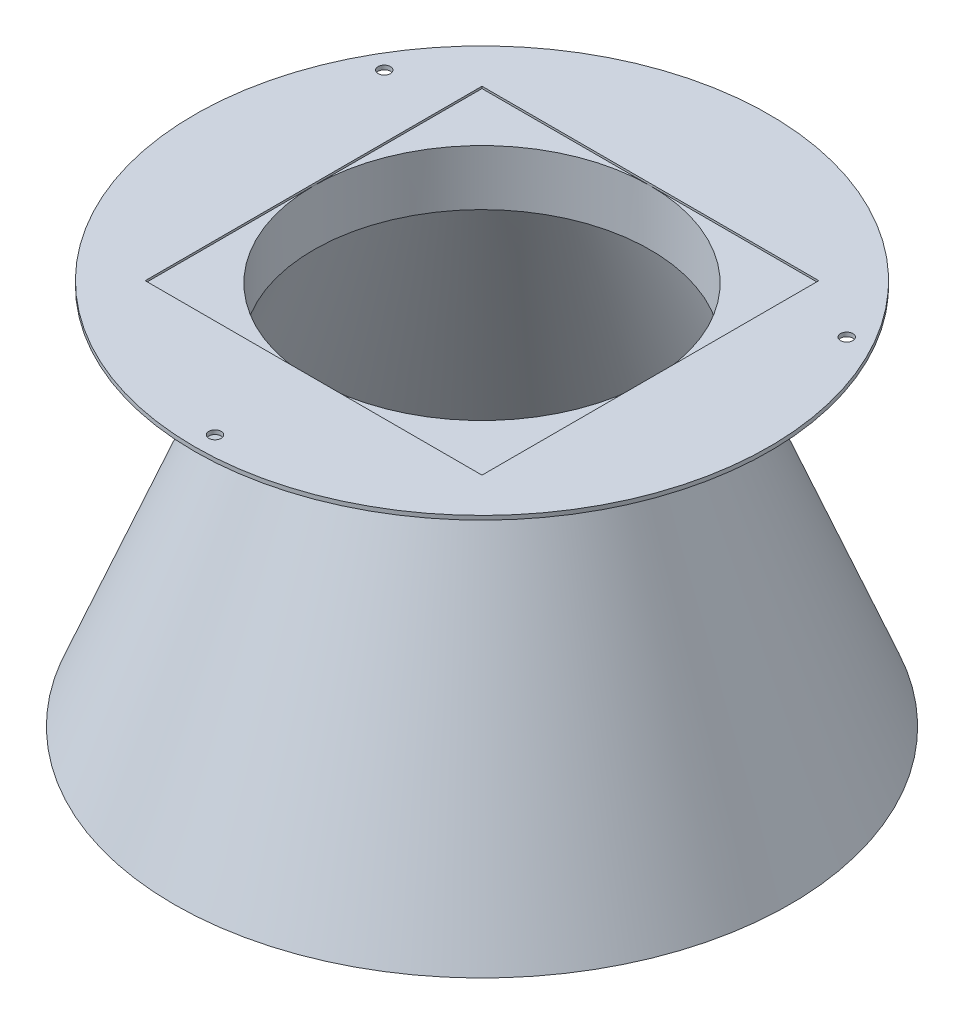
from build123d import *

# Parameters (mm, degrees)
CROQUIS6_R            = 1.5
CORTAR_EXTRUIR9_DEPTH = 10
CROQUIS2_W            = 82
CROQUIS2_H            = 82
CORTAR_EXTRUIR1_DEPTH = 11.5
CROQUIS4_W            = 14
CROQUIS4_H            = 8.5
CORTAR_EXTRUIR2_DEPTH = 10.5


with BuildPart() as part:
    # Croquis1 → Revolución1 (revolve)
    with BuildSketch(Plane.XY):
        Polygon((-67.901642817, 46.97611702), (-67.901642817, 60.97611702), (-96.901642817, 60.97611702), (-96.901642817, 59.97611702), (-86.901642817, 59.97611702), (-69.901642817, 46.97611702), (-101.901642817, -33.02388298), (-99.901642817, -33.02388298), align=None)
    revolve(axis=Axis((-26.901642817, 46.97611702, 0), (0, -1, 0)))

    # Croquis6 → Cortar-Extruir9 (cut)
    with BuildSketch(Plane.XZ.offset(-59.97611702)):
        with Locations((-26.901642817, 65)):
            Circle(CROQUIS6_R)
        with Locations((29.390008429, -32.5)):
            Circle(CROQUIS6_R)
        with Locations((-83.193294063, -32.5)):
            Circle(CROQUIS6_R)
    extrude(amount=-CORTAR_EXTRUIR9_DEPTH, mode=Mode.SUBTRACT)

    # Croquis2 → Cortar-Extruir1 (cut)
    with BuildSketch(Plane(origin=(0, 71.97611702, 0), x_dir=(1, 0, 0), z_dir=(0, 1, 0))):
        with Locations((-26.901642817, 0)):
            Rectangle(CROQUIS2_W, CROQUIS2_H)
    extrude(amount=-CORTAR_EXTRUIR1_DEPTH, mode=Mode.SUBTRACT)

    # Croquis4 → Cortar-Extruir2 (cut)
    with BuildSketch(Plane.ZY.offset(-25.098357183)):
        with Locations((0, 77.22611702)):
            Rectangle(CROQUIS4_W, CROQUIS4_H)
    extrude(amount=-CORTAR_EXTRUIR2_DEPTH, mode=Mode.SUBTRACT)


solid = part.part
